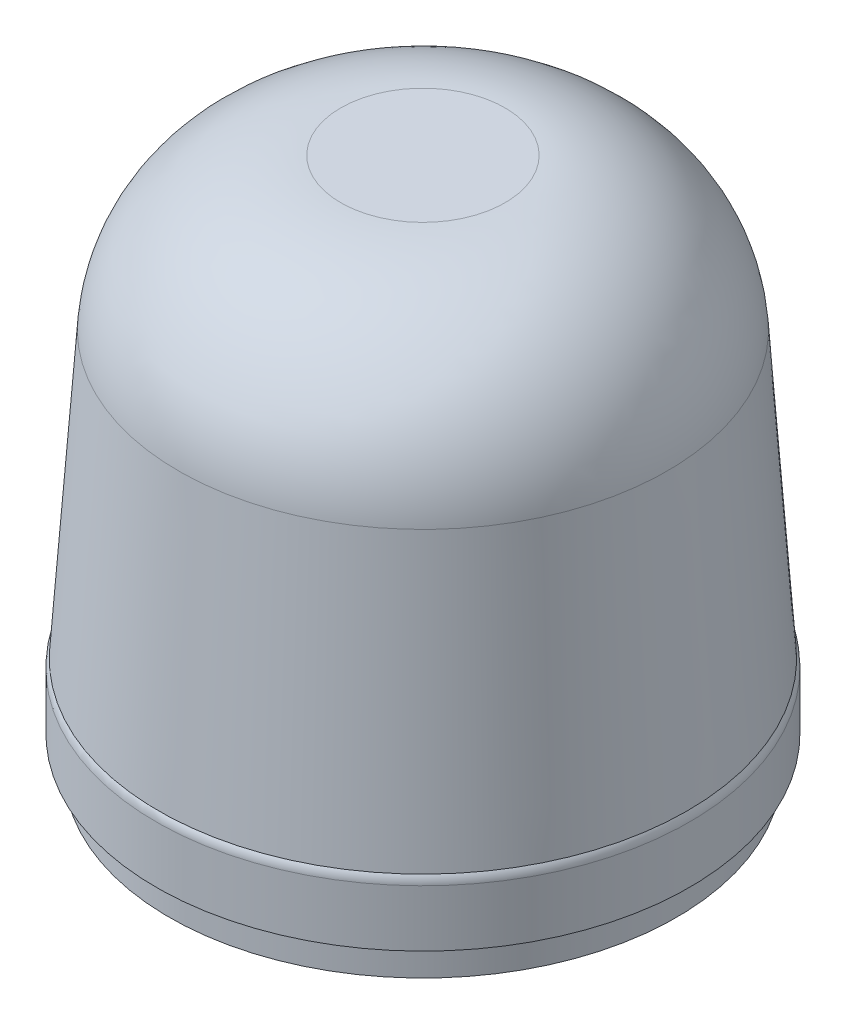
from build123d import *

# Parameters (mm, degrees)
CIRPATTERN1_COUNT = 4
CIRPATTERN2_COUNT = 3
SCALE2_SCALE      = 0.5
SCALE3_SCALE      = 0.5


with BuildPart() as part:
    # Sketch1 → Revolve1 (revolve)
    with BuildSketch(Plane.XY):
        with BuildLine():
            Line((0, 0), (-78, 0))
            Line((-78, 0), (-78, 8))
            Line((-78, 8), (-82, 10))
            Line((-82, 10), (-82, 27.409008705))
            ThreePointArc((-82, 27.409008705), (-81.815678203, 28.754089909), (-81.276302621, 30))
            Line((-81.276302621, 30), (-75.158558027, 117.487823687))
            ThreePointArc((-75.158558027, 117.487823687), (-59.380273517, 150.567685081), (-25.280355514, 164))
            Line((-25.280355514, 164), (0, 164))
            Line((0, 164), (0, 0))
        make_face()
    revolve(axis=Axis((0, 164, 0), (0, -1, 0)))

    # Sketch5 → Ø4.0 (4) Diameter Hole1 (revolve, cut)
    with BuildSketch(Plane(origin=(-26.870057685, 0, 26.870057685), x_dir=(0, 0, -1), z_dir=(1, 0, 0))):
        Polygon((0, 0), (0, 20.201721238), (2, 19), (2, 0), align=None)
    f_4_0_4_diameter_hole1 = revolve(axis=Axis((-26.870057685, -6.35, 26.870057685), (0, 1, 0)), mode=Mode.SUBTRACT)

    # CirPattern1: Ø4.0 (4) Diameter Hole1 ×4 about axis
    cirpattern1_axis = Axis((0, 0, 0), (0, 1, 0))
    for i in range(1, CIRPATTERN1_COUNT):
        add(f_4_0_4_diameter_hole1.rotate(cirpattern1_axis, i * 360 / CIRPATTERN1_COUNT), mode=Mode.SUBTRACT)

    # Sketch7 → Ø5.0 (5) Diameter Hole1 (revolve, cut)
    with BuildSketch(Plane(origin=(64.752655376, 0, -5.665123279), x_dir=(0, 0, -1), z_dir=(1, 0, 0))):
        Polygon((0, 0), (0, 20.502151548), (2.5, 19), (2.5, 0), align=None)
    f_5_0_5_diameter_hole1 = revolve(axis=Axis((64.752655376, -6.35, -5.665123279), (0, 1, 0)), mode=Mode.SUBTRACT)

    # CirPattern2: Ø5.0 (5) Diameter Hole1 ×3 about axis
    cirpattern2_axis = Axis((0, 0, 0), (0, 1, 0))
    for i in range(1, CIRPATTERN2_COUNT):
        add(f_5_0_5_diameter_hole1.rotate(cirpattern2_axis, i * 360 / CIRPATTERN2_COUNT), mode=Mode.SUBTRACT)


with BuildPart() as part_1:
    # Scale2: scaled about (0, 74.027875032, 0)
    add(part.part.scale(SCALE2_SCALE).moved(Location((0, 37.013937516, 0))))


with BuildPart() as part_2:
    # Scale3: scaled about (0, 74.027875032, 0)
    add(part_1.part.scale(SCALE3_SCALE).moved(Location((0, 37.013937516, 0))))


solid = part_2.part
